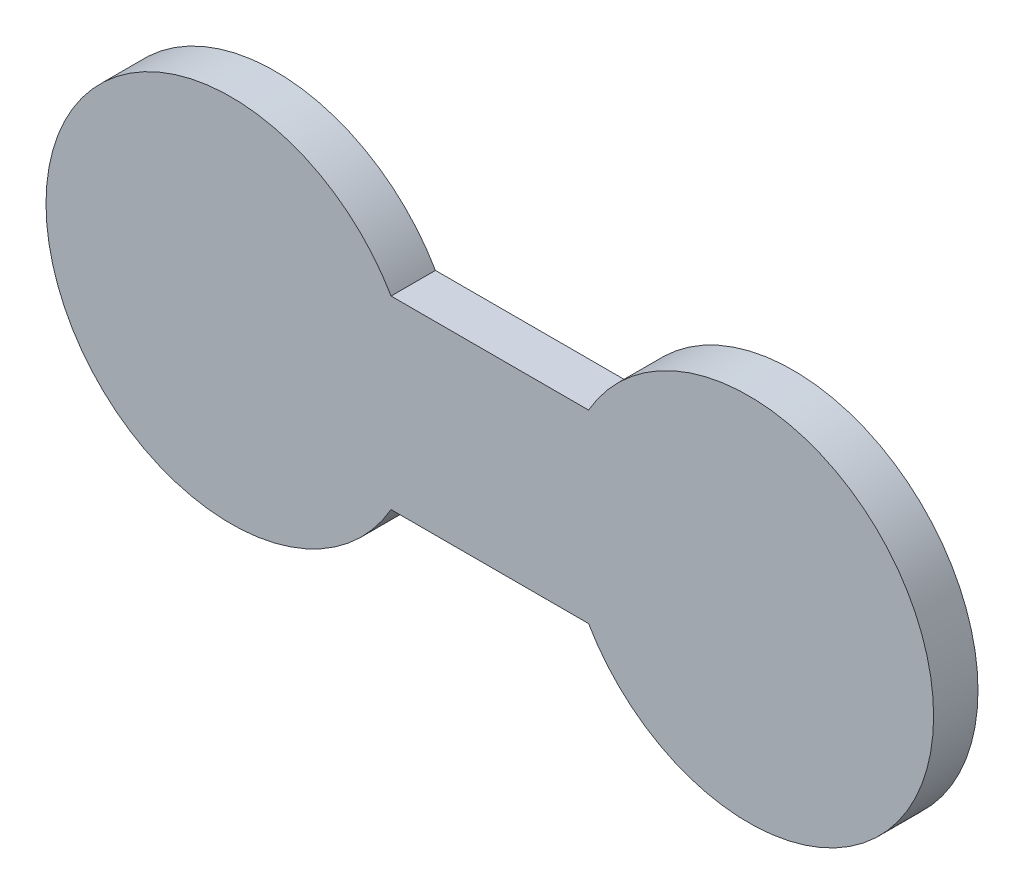
from build123d import *

# Parameters (mm, degrees)
ESQUISSE1_W             = 60
ESQUISSE1_H             = 25
BOSS_EXTRU_2_DEPTH      = 3
ENL_V_MAT_EXTRU_1_DEPTH = 10


with BuildPart() as part:
    # Esquisse1 → Boss.-Extru.2 (new body)
    with BuildSketch(Plane.XY):
        Rectangle(ESQUISSE1_W, ESQUISSE1_H)
    extrude(amount=BOSS_EXTRU_2_DEPTH)

    # Esquisse2 → Enlèv. mat.-Extru.1 (cut)
    with BuildSketch(Plane.XY.offset(3)):
        with BuildLine():
            Line((-6.674682453, 6.25), (0, 6.25))
            Line((0, 6.25), (6.674682453, 6.25))
            ThreePointArc((6.674682453, 6.25), (11.249999964, 10.825317527), (17.499999917, 12.5))
            Line((17.499999917, 12.5), (-17.500000011, 12.5))
            ThreePointArc((-17.500000011, 12.5), (-11.250000005, 10.82531755), (-6.674682453, 6.25))
        make_face()
        with BuildLine():
            ThreePointArc((-30, 3e-08), (-26.338834758, 8.838834771), (-17.500000011, 12.5))
            Line((-17.500000011, 12.5), (-30, 12.5))
            Line((-30, 12.5), (-30, 3e-08))
        make_face()
        with BuildLine():
            Line((-30, -12.5), (-17.50000003, -12.5))
            ThreePointArc((-17.50000003, -12.5), (-26.338834786, -8.838834744), (-30, 3e-08))
            Line((-30, 3e-08), (-30, -12.5))
        make_face()
        with BuildLine():
            Line((6.674682453, -6.25), (0, -6.25))
            Line((0, -6.25), (-6.674682453, -6.25))
            ThreePointArc((-6.674682453, -6.25), (-11.250000013, -10.825317555), (-17.50000003, -12.5))
            Line((-17.50000003, -12.5), (17.500000079, -12.5))
            ThreePointArc((17.500000079, -12.5), (11.250000034, -10.825317567), (6.674682453, -6.25))
        make_face()
        with BuildLine():
            ThreePointArc((30, -1.2e-08), (26.338834789, -8.838834741), (17.500000079, -12.5))
            Line((17.500000079, -12.5), (30, -12.5))
            Line((30, -12.5), (30, -1.2e-08))
        make_face()
        with BuildLine():
            Line((30, 12.5), (17.499999917, 12.5))
            ThreePointArc((17.499999917, 12.5), (26.33883474, 8.83883479), (30, -1.2e-08))
            Line((30, -1.2e-08), (30, 12.5))
        make_face()
    extrude(amount=-ENL_V_MAT_EXTRU_1_DEPTH, mode=Mode.SUBTRACT)


solid = part.part
